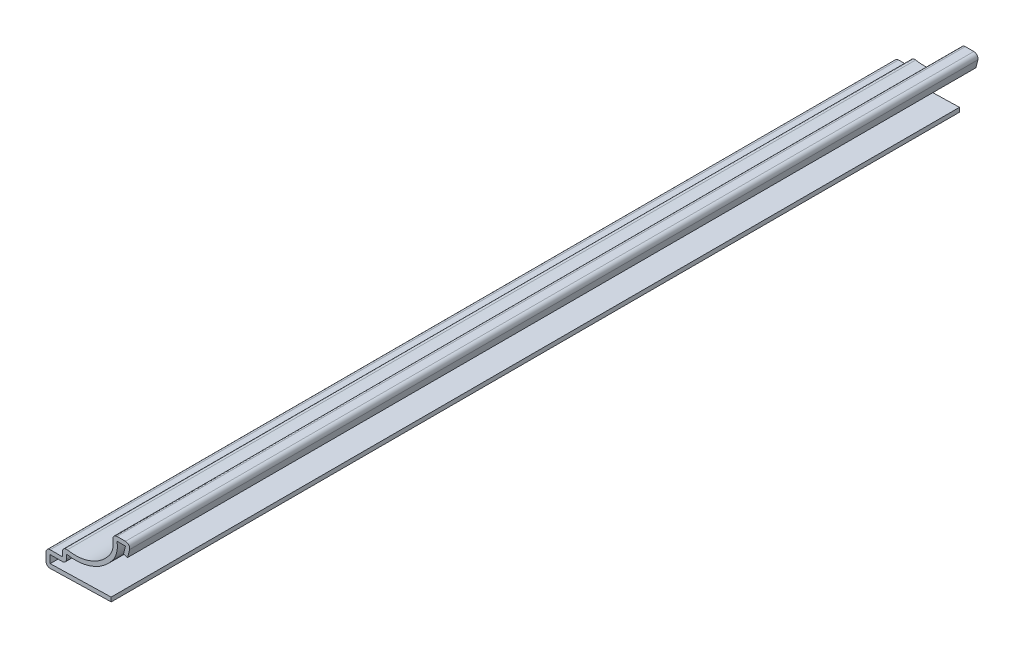
from build123d import *

# Parameters (mm, degrees)
EXTRUDE_THIN1_DEPTH = 206.375
FILLET1_R           = 1.016


with BuildPart() as part:
    # Sketch1 → Extrude-Thin1 (new body)
    with BuildSketch(Plane.XY):
        with BuildLine():
            Line((-0.79375, 11.731625), (0, 14.906625))
            Line((0, 14.906625), (-4.7625, 14.906625))
            ThreePointArc((-4.7625, 14.906625), (-4.309569444, 12.373308652), (-5.240769358, 9.974203708))
            ThreePointArc((-5.240769358, 9.974203708), (-10.374425557, 6.332169642), (-16.66875, 6.35))
            Line((-16.66875, 6.35), (-16.66875, 3.96875))
            Line((-16.66875, 3.96875), (-20.6375, 3.96875))
            Line((-20.6375, 3.96875), (-20.6375, 0))
            Line((-20.6375, 0), (-4.7625, 0.396875))
            Line((-4.7625, 0.396875), (-4.787892066, 1.412557649))
            Line((-4.787892066, 1.412557649), (-19.6215, 1.04171745))
            Line((-19.6215, 1.04171745), (-19.6215, 2.95275))
            Line((-19.6215, 2.95275), (-15.65275, 2.95275))
            Line((-15.65275, 2.95275), (-15.65275, 5.040913964))
            ThreePointArc((-15.65275, 5.040913964), (-9.419658883, 5.590889524), (-4.428168187, 9.364338693))
            ThreePointArc((-4.428168187, 9.364338693), (-3.423343097, 11.516274139), (-3.36895913, 13.890625))
            Line((-3.36895913, 13.890625), (-1.301268829, 13.890625))
            Line((-1.301268829, 13.890625), (-1.77941478, 11.978041195))
            Line((-1.77941478, 11.978041195), (-0.79375, 11.731625))
        make_face()
    extrude(amount=-EXTRUDE_THIN1_DEPTH)

    # Fillet1
    fillet1_edges = [part.edges().sort_by_distance(p)[0] for p in [
        (-20.6375, 0, -103.1875),
        (-20.6375, 3.96875, -103.1875),
        (-16.66875, 6.35, -103.1875),
        (-4.7625, 14.906625, -103.1875),
        (0, 14.906625, -103.1875),
        (-15.65275, 2.95275, -103.1875),
    ]]
    fillet(fillet1_edges, radius=FILLET1_R)


solid = part.part
